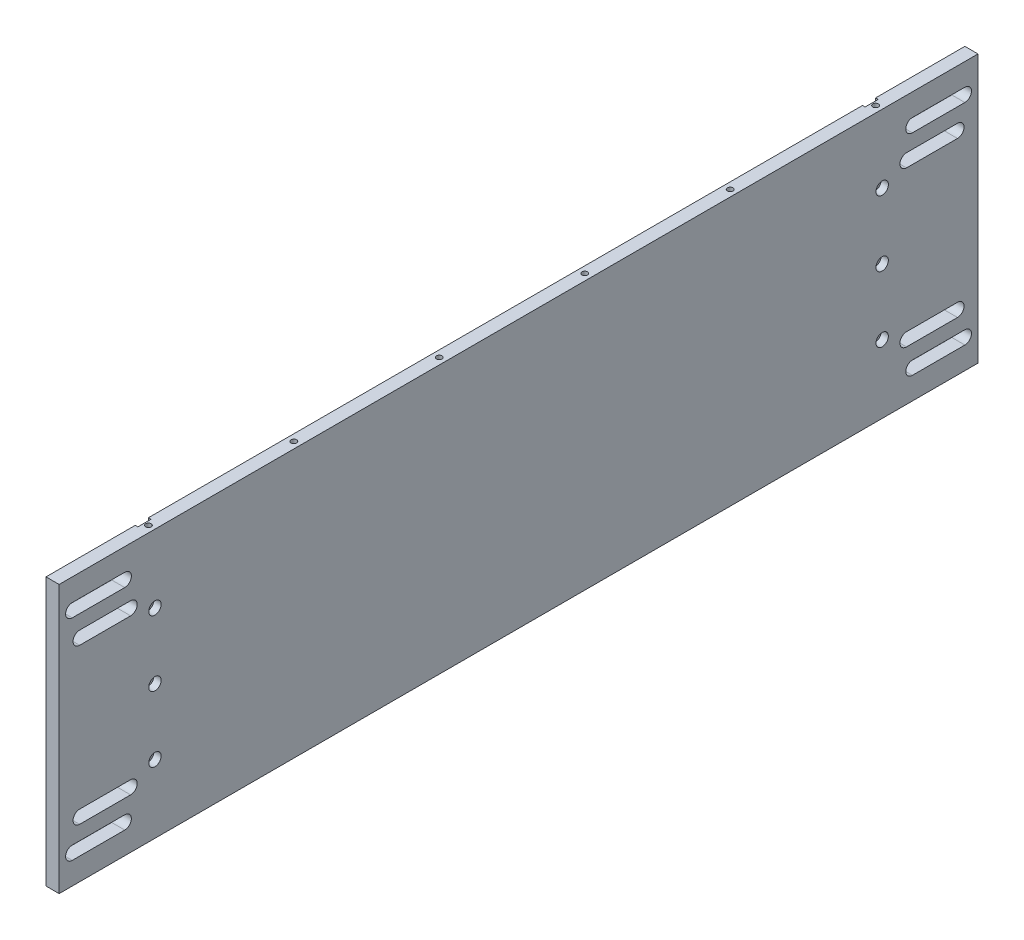
from build123d import *

# Parameters (mm, degrees)
SKETCH1_W                                      = 444.5
SKETCH1_H                                      = 129.54
BOSS_EXTRUDE1_DEPTH                            = 6.35
CBORE_FOR_6_SOCKET_HEAD_CAP_SCREW1_D           = 3.6576
CBORE_FOR_6_SOCKET_HEAD_CAP_SCREW1_CBORE_D     = 5.999999938
CBORE_FOR_6_SOCKET_HEAD_CAP_SCREW1_CBORE_DEPTH = 3.5052
CUT_EXTRUDE1_DEPTH                             = 7.35
TAP_DRILL_FOR_6_32_TAP1_D                      = 2.7051
TAP_DRILL_FOR_6_32_TAP1_DEPTH                  = 17.78
TAP_DRILL_FOR_6_32_TAP1_TIP                    = 0.81269403
TAP_DRILL_FOR_6_32_TAP2_D                      = 2.7051
TAP_DRILL_FOR_6_32_TAP2_DEPTH                  = 17.78
TAP_DRILL_FOR_6_32_TAP2_TIP                    = 0.81269403
SKETCH21_W                                     = 6.35
SKETCH21_H                                     = 129.54
CUT_EXTRUDE2_DEPTH                             = 1.27


with BuildPart() as part:
    # Sketch1 → Boss-Extrude1 (new body)
    with BuildSketch(Plane(origin=(0, 0, 0), x_dir=(0, 0, -1), z_dir=(1, 0, 0))):
        with Locations((222.25, 64.77)):
            Rectangle(SKETCH1_W, SKETCH1_H)
    extrude(amount=BOSS_EXTRUDE1_DEPTH)

    # CBORE for #6 Socket Head Cap Screw1 (through all)
    with Locations(Plane(origin=(6.35, 0, 0), x_dir=(0, 0, -1), z_dir=(1, 0, 0))):
        with Locations((46.355, 64.77), (398.145, 64.77), (46.355, 96.52), (46.355, 33.02), (398.145, 96.52), (398.145, 33.02)):
            CounterBoreHole(CBORE_FOR_6_SOCKET_HEAD_CAP_SCREW1_D / 2, CBORE_FOR_6_SOCKET_HEAD_CAP_SCREW1_CBORE_D / 2, CBORE_FOR_6_SOCKET_HEAD_CAP_SCREW1_CBORE_DEPTH)

    # Sketch16 → Cut-Extrude1 (cut, through all)
    with BuildSketch(Plane(origin=(6.35, 0, 0), x_dir=(0, 0, -1), z_dir=(1, 0, 0))):
        with BuildLine():
            Line((6.35, 118.7704), (31.75, 118.7704))
            ThreePointArc((31.75, 118.7704), (34.9504, 115.57), (31.75, 112.3696))
            Line((31.75, 112.3696), (6.35, 112.3696))
            ThreePointArc((6.35, 112.3696), (3.1496, 115.57), (6.35, 118.7704))
        make_face()
        with BuildLine():
            Line((434.5817, 24.095), (409.9183, 24.095))
            ThreePointArc((409.9183, 24.095), (406.7433, 27.27), (409.9183, 30.445))
            Line((409.9183, 30.445), (434.5817, 30.445))
            ThreePointArc((434.5817, 30.445), (437.7567, 27.27), (434.5817, 24.095))
        make_face()
        with BuildLine():
            Line((434.5817, 105.445), (409.9183, 105.445))
            ThreePointArc((409.9183, 105.445), (406.7433, 102.27), (409.9183, 99.095))
            Line((409.9183, 99.095), (434.5817, 99.095))
            ThreePointArc((434.5817, 99.095), (437.7567, 102.27), (434.5817, 105.445))
        make_face()
        with BuildLine():
            Line((6.35, 10.7696), (31.75, 10.7696))
            ThreePointArc((31.75, 10.7696), (34.9504, 13.97), (31.75, 17.1704))
            Line((31.75, 17.1704), (6.35, 17.1704))
            ThreePointArc((6.35, 17.1704), (3.1496, 13.97), (6.35, 10.7696))
        make_face()
        with BuildLine():
            Line((438.15, 118.7704), (412.75, 118.7704))
            ThreePointArc((412.75, 118.7704), (409.5496, 115.57), (412.75, 112.3696))
            Line((412.75, 112.3696), (438.15, 112.3696))
            ThreePointArc((438.15, 112.3696), (441.3504, 115.57), (438.15, 118.7704))
        make_face()
        with BuildLine():
            Line((9.9183, 105.445), (34.5817, 105.445))
            ThreePointArc((34.5817, 105.445), (37.7567, 102.27), (34.5817, 99.095))
            Line((34.5817, 99.095), (9.9183, 99.095))
            ThreePointArc((9.9183, 99.095), (6.7433, 102.27), (9.9183, 105.445))
        make_face()
        with BuildLine():
            Line((9.9183, 24.095), (34.5817, 24.095))
            ThreePointArc((34.5817, 24.095), (37.7567, 27.27), (34.5817, 30.445))
            Line((34.5817, 30.445), (9.9183, 30.445))
            ThreePointArc((9.9183, 30.445), (6.7433, 27.27), (9.9183, 24.095))
        make_face()
        with BuildLine():
            Line((438.15, 10.7696), (412.75, 10.7696))
            ThreePointArc((412.75, 10.7696), (409.5496, 13.97), (412.75, 17.1704))
            Line((412.75, 17.1704), (438.15, 17.1704))
            ThreePointArc((438.15, 17.1704), (441.3504, 13.97), (438.15, 10.7696))
        make_face()
    extrude(amount=-CUT_EXTRUDE1_DEPTH, mode=Mode.SUBTRACT)

    # Tap Drill for #6-32 Tap1
    with Locations(Plane(origin=(-408.187088364, 129.54, -132.107048836), x_dir=(0, 0, -1), z_dir=(0, 1, 0))):
        with Locations((-85.752048836, -59.572088364), (-15.394048836, -59.572088364), (54.963951164, -59.572088364), (125.321951164, -59.572088364), (195.679951164, -59.572088364), (266.037951164, -59.572088364), (266.037951164, -129.930088364), (266.037951164, -200.288088364), (266.037951164, -270.646088364), (266.037951164, -341.004088364), (266.037951164, -411.362088364), (195.679951164, -411.362088364), (125.321951164, -411.362088364), (54.963951164, -411.362088364), (-15.394048836, -411.362088364), (-85.752048836, -411.362088364), (-85.752048836, -341.004088364), (-85.752048836, -270.646088364), (-85.752048836, -200.288088364), (-85.752048836, -129.930088364)):
            Hole(TAP_DRILL_FOR_6_32_TAP1_D / 2, depth=TAP_DRILL_FOR_6_32_TAP1_DEPTH)
            with Locations((0, 0, -(TAP_DRILL_FOR_6_32_TAP1_DEPTH + TAP_DRILL_FOR_6_32_TAP1_TIP / 2))):  # 118° drill point
                Cone(0, TAP_DRILL_FOR_6_32_TAP1_D / 2, TAP_DRILL_FOR_6_32_TAP1_TIP, mode=Mode.SUBTRACT)

    # Tap Drill for #6-32 Tap2
    with Locations(Plane(origin=(62.772488364, 0, -312.367551164), x_dir=(0, 0, -1), z_dir=(0, -1, 0))):
        with Locations((85.752048836, -411.362088364), (15.394048836, -411.362088364), (-54.963951164, -411.362088364), (-125.321951164, -411.362088364), (-195.679951164, -411.362088364), (-266.037951164, -411.362088364), (-266.037951164, -341.004088364), (-266.037951164, -270.646088364), (-266.037951164, -200.288088364), (-266.037951164, -129.930088364), (-266.037951164, -59.572088364), (-195.679951164, -59.572088364), (-125.321951164, -59.572088364), (-54.963951164, -59.572088364), (15.394048836, -59.572088364), (85.752048836, -59.572088364), (85.752048836, -130.006288364), (85.752048836, -200.364288364), (85.752048836, -270.722288364), (85.752048836, -341.080288364)):
            Hole(TAP_DRILL_FOR_6_32_TAP2_D / 2, depth=TAP_DRILL_FOR_6_32_TAP2_DEPTH)
            with Locations((0, 0, -(TAP_DRILL_FOR_6_32_TAP2_DEPTH + TAP_DRILL_FOR_6_32_TAP2_TIP / 2))):  # 118° drill point
                Cone(0, TAP_DRILL_FOR_6_32_TAP2_D / 2, TAP_DRILL_FOR_6_32_TAP2_TIP, mode=Mode.SUBTRACT)

    # Sketch21 → Cut-Extrude2 (cut)
    with BuildSketch(Plane.ZY):
        with Locations((-398.145, 64.77)):
            Rectangle(SKETCH21_W, SKETCH21_H)
        with Locations((-46.355, 64.77)):
            Rectangle(SKETCH21_W, SKETCH21_H)
    extrude(amount=-CUT_EXTRUDE2_DEPTH, mode=Mode.SUBTRACT)


solid = part.part
